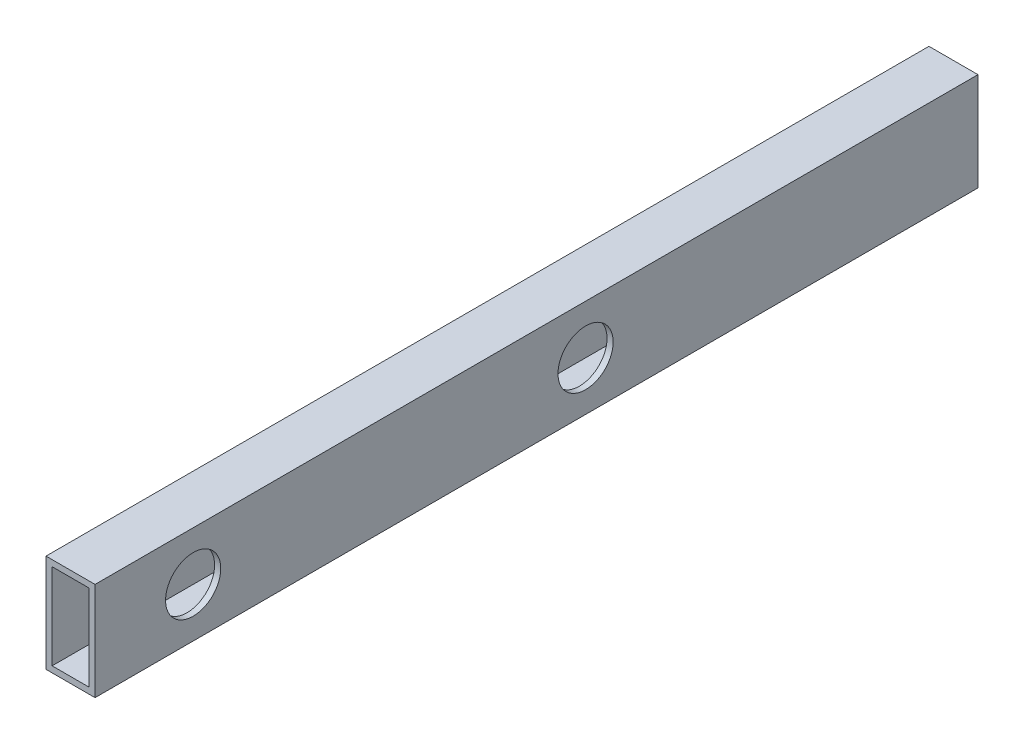
from build123d import *

# Parameters (mm, degrees)
SKETCH1_W           = 25.4
SKETCH1_H           = 50.8
SKETCH1_W_2         = 19.05
SKETCH1_H_2         = 44.45
BOSS_EXTRUDE1_DEPTH = 457.2
SKETCH2_R           = 14.2875
CUT_EXTRUDE1_DEPTH  = 26.4


with BuildPart() as part:
    # Sketch1 → Boss-Extrude1 (new body)
    with BuildSketch(Plane.XY):
        with Locations((12.7, 25.4)):
            Rectangle(SKETCH1_W, SKETCH1_H)
        with Locations((12.7, 25.4)):
            Rectangle(SKETCH1_W_2, SKETCH1_H_2, mode=Mode.SUBTRACT)
    extrude(amount=BOSS_EXTRUDE1_DEPTH)

    # Sketch2 → Cut-Extrude1 (cut, through all)
    with BuildSketch(Plane(origin=(25.4, 0, 0), x_dir=(0, 0, -1), z_dir=(1, 0, 0))):
        with Locations((-406.4, 25.4)):
            Circle(SKETCH2_R)
        with Locations((-203.2, 25.4)):
            Circle(SKETCH2_R)
    extrude(amount=-CUT_EXTRUDE1_DEPTH, mode=Mode.SUBTRACT)


solid = part.part
